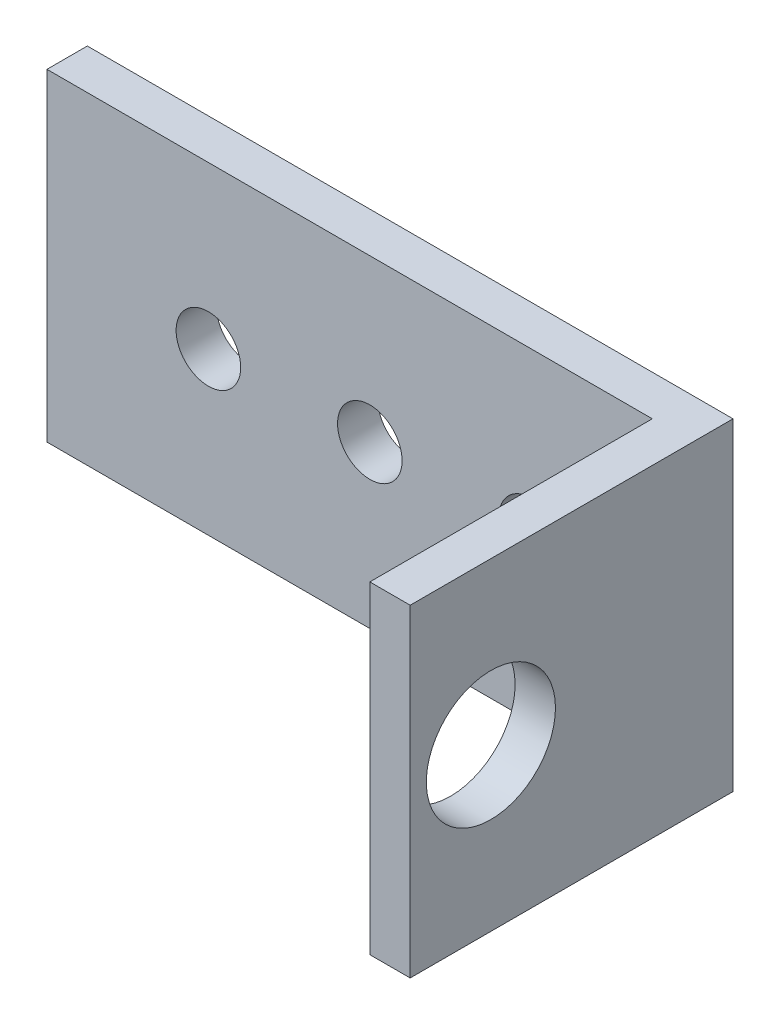
from build123d import *

# Parameters (mm, degrees)
BOSS_EXTRUDE1_DEPTH = 25.4
SKETCH2_R           = 5.08
CUT_EXTRUDE1_DEPTH  = 3.175
SKETCH3_R           = 2.54
CUT_EXTRUDE2_DEPTH  = 3.175


with BuildPart() as part:
    # Sketch1 → Boss-Extrude1 (new body)
    with BuildSketch(Plane(origin=(0, 0, 0), x_dir=(1, 0, 0), z_dir=(0, 1, 0))):
        Polygon((22.225, 9.525), (22.225, -12.7), (25.4, -12.7), (25.4, 12.7), (-25.4, 12.7), (-25.4, 9.525), align=None)
    extrude(amount=BOSS_EXTRUDE1_DEPTH)

    # Sketch2 → Cut-Extrude1 (cut)
    with BuildSketch(Plane(origin=(25.4, 0, 0), x_dir=(0, 0, -1), z_dir=(1, 0, 0))):
        with Locations((-6.35, 12.7)):
            Circle(SKETCH2_R)
    extrude(amount=-CUT_EXTRUDE1_DEPTH, mode=Mode.SUBTRACT)

    # Sketch3 → Cut-Extrude2 (cut)
    with BuildSketch(Plane.XY.offset(-9.525)):
        with Locations((-12.7, 12.7)):
            Circle(SKETCH3_R)
        with Locations((0, 12.7)):
            Circle(SKETCH3_R)
        with Locations((12.7, 12.7)):
            Circle(SKETCH3_R)
    extrude(amount=-CUT_EXTRUDE2_DEPTH, mode=Mode.SUBTRACT)


solid = part.part
